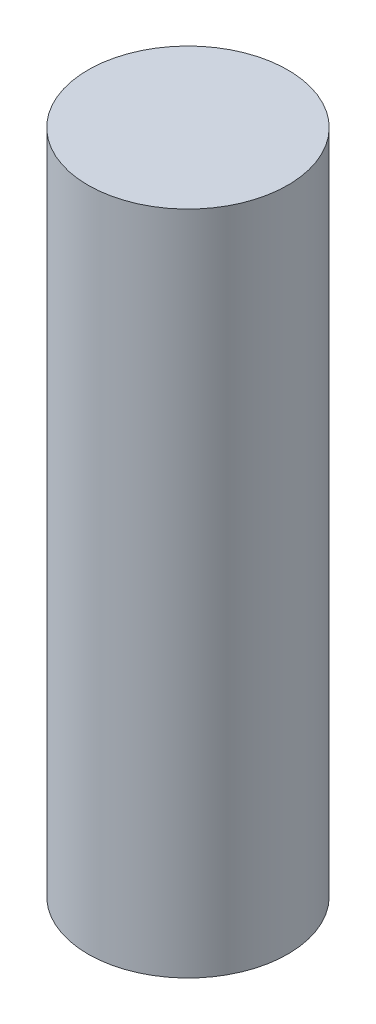
from build123d import *

# Parameters (mm, degrees)
SKETCH_1_R      = 3
EXTRUDE_1_DEPTH = 20


with BuildPart() as part:
    # 草图1 → 凸台-拉伸1 (new body)
    with BuildSketch(Plane(origin=(0, 0, 0), x_dir=(1, 0, 0), z_dir=(0, 1, 0))):
        Circle(SKETCH_1_R)
    extrude(amount=EXTRUDE_1_DEPTH)


solid = part.part
